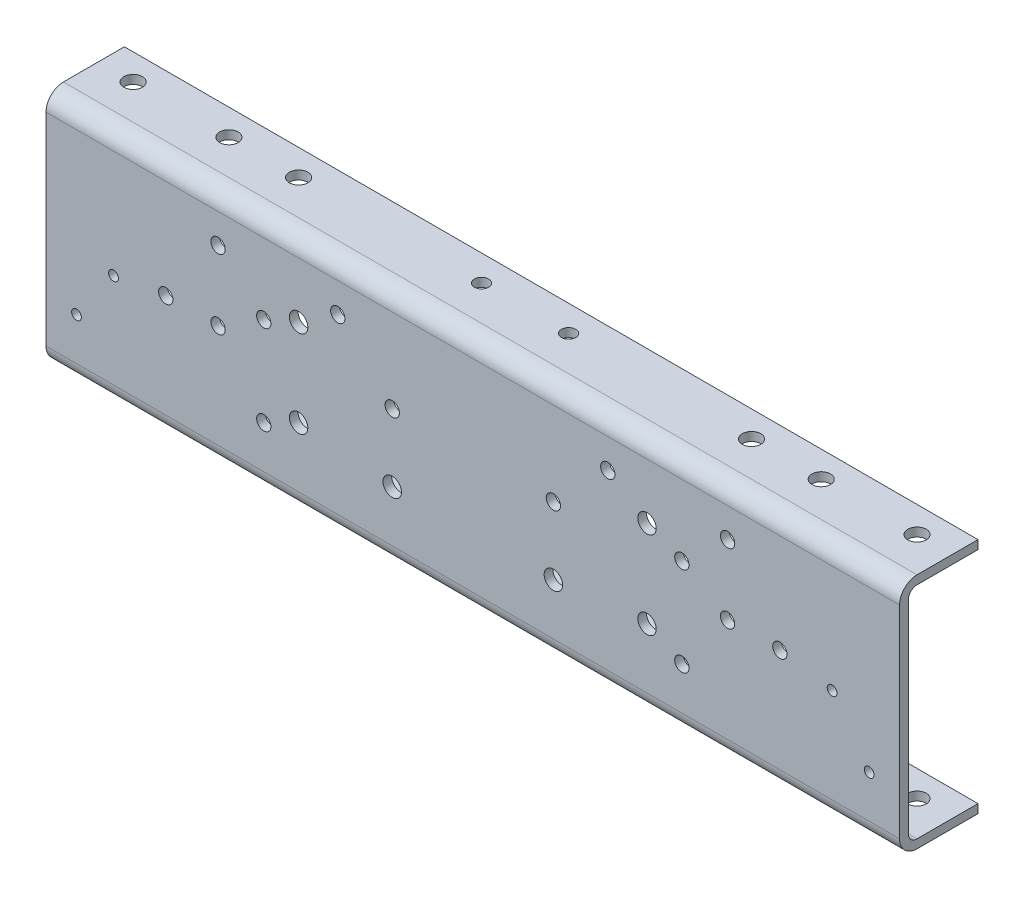
from build123d import *

# Parameters (mm, degrees)
EXTRUDE1_DEPTH           = 311.15
SKETCH2_R                = 5.207
SKETCH2_R_2              = 3.556
SKETCH2_R_3              = 6.731
CUT_WEB_HOLES_DEPTH      = 328.972466987
SKETCH3_R                = 6.731
SKETCH3_R_2              = 5.207
CUT_FLG_HOLES_DEPTH      = 328.972466987
CUT_FLG_HOLES_DEPTH_BACK = 328.972466987


with BuildPart() as part:
    # Sketch1 → Extrude1 (new, symmetric)
    with BuildSketch(Plane(origin=(0, 0, 0), x_dir=(0, 0, -1), z_dir=(1, 0, 0))):
        with BuildLine():
            Line((57.15, 86.51875), (12.7, 86.51875))
            ThreePointArc((12.7, 86.51875), (3.719743879, 82.799006121), (0, 73.81875))
            Line((0, 73.81875), (0, -73.81875))
            ThreePointArc((0, -73.81875), (3.719743879, -82.799006121), (12.7, -86.51875))
            Line((12.7, -86.51875), (57.15, -86.51875))
            Line((57.15, -86.51875), (57.15, -80.16875))
            Line((57.15, -80.16875), (12.7, -80.16875))
            ThreePointArc((12.7, -80.16875), (8.209871939, -78.308878061), (6.35, -73.81875))
            Line((6.35, -73.81875), (6.35, 73.81875))
            ThreePointArc((6.35, 73.81875), (8.209871939, 78.308878061), (12.7, 80.16875))
            Line((12.7, 80.16875), (57.15, 80.16875))
            Line((57.15, 80.16875), (57.15, 86.51875))
        make_face()
    extrude(amount=EXTRUDE1_DEPTH, both=True)

    # Sketch2 → Cut-Web Holes (cut, through all)
    with BuildSketch(Plane.XY):
        with Locations(Location((-152.4, 22.225, 0), (0, 0, 270))):
            Circle(SKETCH2_R)
        with Locations(Location((-185.7375, 52.3875, 0), (0, 0, 270))):
            Circle(SKETCH2_R)
        with Locations(Location((-223.8375, 1.5875, 0), (0, 0, 270))):
            Circle(SKETCH2_R)
        with Locations(Location((-261.9375, -4.7625, 0), (0, 0, 270))):
            Circle(SKETCH2_R_2)
        with Locations(Location((-288.925, -42.8625, 0), (0, 0, 270))):
            Circle(SKETCH2_R_2)
        with Locations(Location((-152.4, -42.8625, 0), (0, 0, 270))):
            Circle(SKETCH2_R)
        with Locations(Location((-127, -30.1625, 0), (0, 0, 270))):
            Circle(SKETCH2_R_3)
        with Locations(Location((-127, 33.3375, 0), (0, 0, 270))):
            Circle(SKETCH2_R_3)
        with Locations(Location((-98.425, 52.3875, 0), (0, 0, 270))):
            Circle(SKETCH2_R)
        with Locations(Location((-58.7375, 12.7, 0), (0, 0, 270))):
            Circle(SKETCH2_R)
        with Locations(Location((-58.7375, -36.5125, 0), (0, 0, 270))):
            Circle(SKETCH2_R_3)
        with Locations(Location((-185.7375, 1.5875, 0), (0, 0, 270))):
            Circle(SKETCH2_R)
        with Locations((98.425, 52.3875)):
            Circle(SKETCH2_R)
        with Locations((127, 33.3375)):
            Circle(SKETCH2_R_3)
        with Locations((152.4, 22.225)):
            Circle(SKETCH2_R)
        with Locations((185.7375, 52.3875)):
            Circle(SKETCH2_R)
        with Locations((223.8375, 1.5875)):
            Circle(SKETCH2_R)
        with Locations((185.7375, 1.5875)):
            Circle(SKETCH2_R)
        with Locations((261.9375, -4.7625)):
            Circle(SKETCH2_R_2)
        with Locations((288.925, -42.8625)):
            Circle(SKETCH2_R_2)
        with Locations((152.4, -42.8625)):
            Circle(SKETCH2_R)
        with Locations((127, -30.1625)):
            Circle(SKETCH2_R_3)
        with Locations((58.7375, 12.7)):
            Circle(SKETCH2_R)
        with Locations((58.7375, -36.5125)):
            Circle(SKETCH2_R_3)
    extrude(amount=-CUT_WEB_HOLES_DEPTH, mode=Mode.SUBTRACT)

    # Sketch3 → Cut-Flg Holes (cut, two sides)
    with BuildSketch(Plane(origin=(0, 0, 0), x_dir=(1, 0, 0), z_dir=(0, 1, 0))) as cut_flg_holes_sk:
        with Locations(Location((-285.75, 38.1, 0), (0, 0, 270))):
            Circle(SKETCH3_R)
        with Locations(Location((-215.9, 38.1, 0), (0, 0, 270))):
            Circle(SKETCH3_R)
        with Locations(Location((285.75, 38.1, 0), (0, 0, 90))):
            Circle(SKETCH3_R)
        with Locations(Location((215.9, 38.1, 0), (0, 0, 90))):
            Circle(SKETCH3_R)
        with Locations(Location((165.1, 38.1, 0), (0, 0, 270))):
            Circle(SKETCH3_R)
        with Locations(Location((31.75, 38.1, 0), (0, 0, 270))):
            Circle(SKETCH3_R_2)
        with Locations(Location((-31.75, 38.1, 0), (0, 0, 270))):
            Circle(SKETCH3_R_2)
        with Locations(Location((-165.1, 38.1, 0), (0, 0, 270))):
            Circle(SKETCH3_R)
    extrude(amount=CUT_FLG_HOLES_DEPTH, mode=Mode.SUBTRACT)
    extrude(cut_flg_holes_sk.sketch, amount=-CUT_FLG_HOLES_DEPTH_BACK, mode=Mode.SUBTRACT)


solid = part.part
